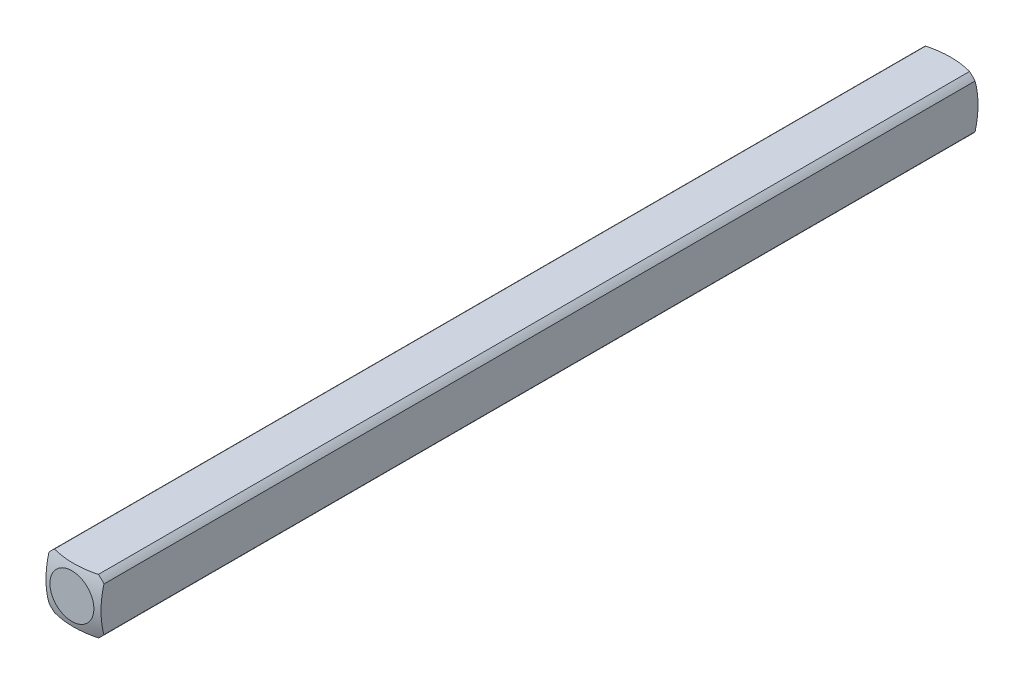
from build123d import *

# Parameters (mm, degrees)
SKETCH1_W           = 3.175
SKETCH1_H           = 3.175
BOSS_EXTRUDE1_DEPTH = 25.4
SKETCH2_OUTSIDE_W   = 10.334
SKETCH2_OUTSIDE_H   = 10.334
SKETCH2_OUTSIDE_R   = 2.032
CUT_EXTRUDE1_DEPTH  = 26.4


with BuildPart() as part:
    # Sketch1 → Boss-Extrude1 (new body)
    with BuildSketch(Plane.XY):
        Rectangle(SKETCH1_W, SKETCH1_H)
    extrude(amount=BOSS_EXTRUDE1_DEPTH)

    # Sketch2 outside → Cut-Extrude1 (cut, through all)
    with BuildSketch(Plane(origin=(0, 0, 0), x_dir=(-1, 0, 0), z_dir=(0, 0, -1))):
        Rectangle(SKETCH2_OUTSIDE_W, SKETCH2_OUTSIDE_H)
        Circle(SKETCH2_OUTSIDE_R, mode=Mode.SUBTRACT)
    extrude(amount=-CUT_EXTRUDE1_DEPTH, mode=Mode.SUBTRACT)

    # Sketch3 → Cut-Revolve1 (revolve, cut)
    with BuildSketch(Plane(origin=(0, 0, 0), x_dir=(1, 0, 0), z_dir=(0, 1, 0))):
        with BuildLine():
            Line((-5.053685963, -4.40273269), (-5.053685963, 5.740530545))
            Line((-5.053685963, 5.740530545), (0, 5.740530545))
            Line((0, 5.740530545), (0, 0.160877736))
            ThreePointArc((0, 0.160877736), (-3.404639553, -1.148866368), (-5.053685963, -4.40273269))
        make_face()
    revolve(axis=Axis((0, 0, 25.4), (0, 0, -1)), mode=Mode.SUBTRACT)

    # Mirror1: part across plane


with BuildPart() as part_1:
    add(part.part)
    add(part.part.mirror(Plane(origin=(0, 0, 25.4), x_dir=(1, 0, 0), z_dir=(0, 0, -1))))


solid = part_1.part
